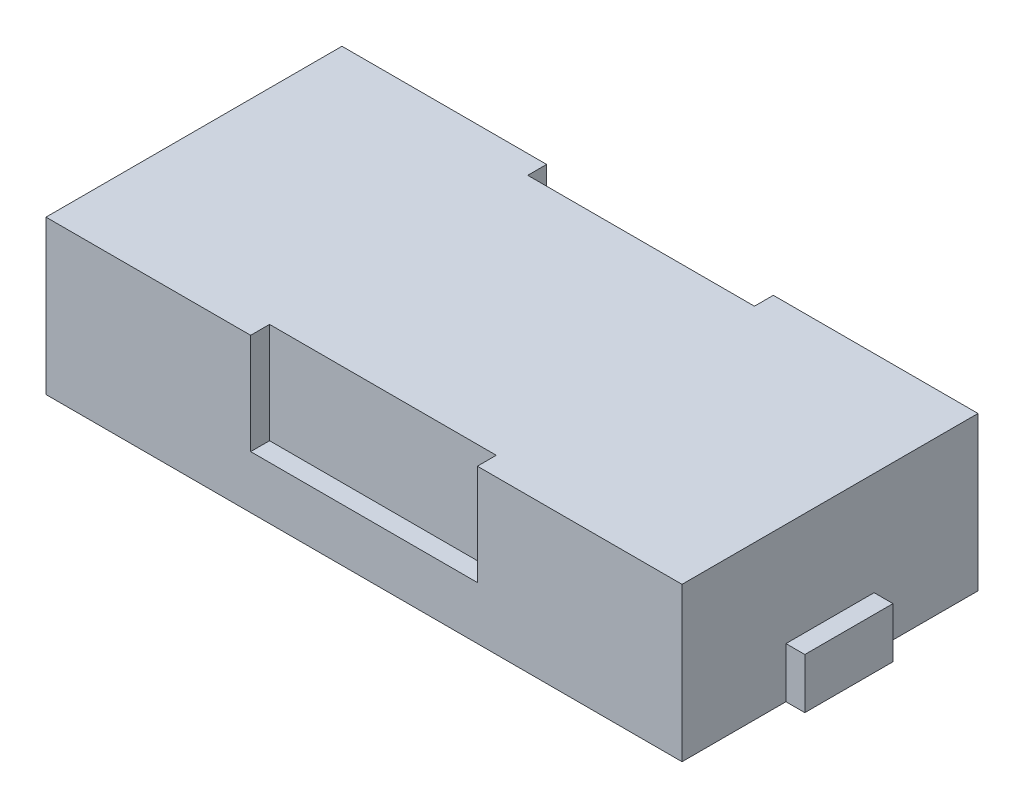
from build123d import *

# Parameters (mm, degrees)
SKETCH_1_W          = 50.5
SKETCH_1_H          = 23.5
EXTRUDE_1_DEPTH     = 12.2
SKETCH_2_W          = 7
SKETCH_2_H          = 4
EXTRUDE_2_DEPTH     = 1.5
SKETCH_3_W          = 18
SKETCH_3_H          = 8
CUT_EXTRUDE_1_DEPTH = 1.5


with BuildPart() as part:
    # Эскиз1 → Бобышка-Вытянуть1 (new body)
    with BuildSketch(Plane(origin=(0, 0, 0), x_dir=(1, 0, 0), z_dir=(0, 1, 0))):
        Rectangle(SKETCH_1_W, SKETCH_1_H)
    extrude(amount=EXTRUDE_1_DEPTH)

    # Эскиз2 → Бобышка-Вытянуть2 (add)
    with BuildSketch(Plane(origin=(25.25, 0, 0), x_dir=(0, 0, -1), z_dir=(1, 0, 0))):
        with Locations((0, 2)):
            Rectangle(SKETCH_2_W, SKETCH_2_H)
    extrude(amount=EXTRUDE_2_DEPTH)

    # Эскиз3 → Вырез-Вытянуть1 (cut)
    with BuildSketch(Plane.XY.offset(11.75)):
        with Locations((0, 8.2)):
            Rectangle(SKETCH_3_W, SKETCH_3_H)
    cut_extrude_1 = extrude(amount=-CUT_EXTRUDE_1_DEPTH, mode=Mode.SUBTRACT)

    # Зеркальное отражение1: Вырез-Вытянуть1 across plane
    add(cut_extrude_1.mirror(Plane.XY), mode=Mode.SUBTRACT)


solid = part.part
